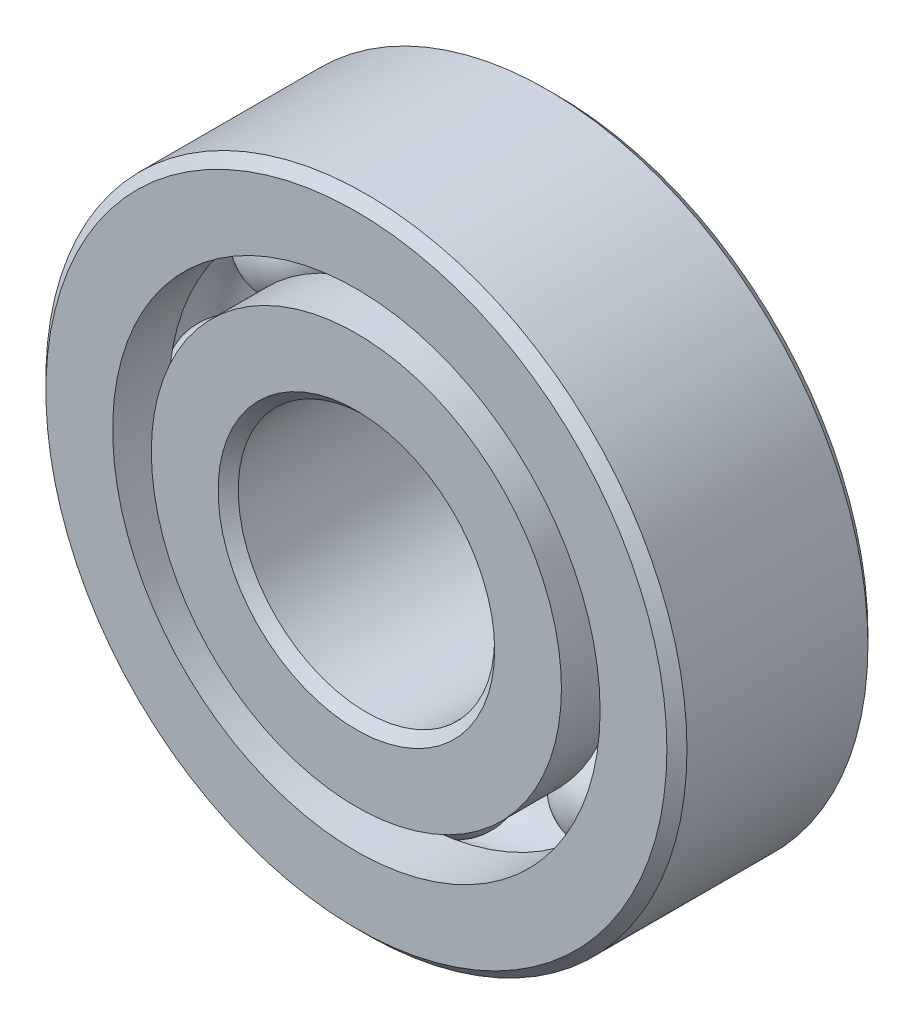
from build123d import *

# Parameters (mm, degrees)
CIRPATTERN1_COUNT = 8


with BuildPart() as part:
    # Sketch1 → Revolve1 (revolve)
    with BuildSketch(Plane(origin=(0, 0, 0), x_dir=(0, 0, -1), z_dir=(1, 0, 0))):
        with BuildLine():
            Line((2.24028, 7.9375), (-2.24028, 7.9375))
            Line((-2.24028, 7.9375), (-2.4892, 7.68858))
            Line((-2.4892, 7.68858), (-2.4892, 6.035221429))
            Line((-2.4892, 6.035221429), (-1.106311111, 6.035221429))
            ThreePointArc((-1.106311111, 6.035221429), (0, 6.76179465), (1.106311111, 6.035221429))
            Line((1.106311111, 6.035221429), (2.4892, 6.035221429))
            Line((2.4892, 6.035221429), (2.4892, 7.68858))
            Line((2.4892, 7.68858), (2.24028, 7.9375))
        make_face()
    revolve(axis=Axis((0, 0, 2.4892), (0, 0, -1)))


with BuildPart() as body_2:
    # Sketch3 → Revolve3 (revolve)
    with BuildSketch(Plane(origin=(0, 0, 0), x_dir=(0, 0, -1), z_dir=(1, 0, 0))):
        with BuildLine():
            Line((-2.4892, 5.077278571), (-1.106311111, 5.077278571))
            ThreePointArc((-1.106311111, 5.077278571), (0, 4.35070535), (1.106311111, 5.077278571))
            Line((1.106311111, 5.077278571), (2.4892, 5.077278571))
            Line((2.4892, 5.077278571), (2.4892, 3.42392))
            Line((2.4892, 3.42392), (2.24028, 3.175))
            Line((2.24028, 3.175), (-2.24028, 3.175))
            Line((-2.24028, 3.175), (-2.4892, 3.42392))
            Line((-2.4892, 3.42392), (-2.4892, 5.077278571))
        make_face()
    revolve(axis=Axis((0, 0, 2.4892), (0, 0, -1)))


with BuildPart() as body_3:
    # Sketch4 → Revolve4 (revolve)
    with BuildSketch(Plane(origin=(0, 0, 0), x_dir=(0, 0, -1), z_dir=(1, 0, 0))):
        with BuildLine():
            Line((-1.20554465, 5.55625), (1.20554465, 5.55625))
            ThreePointArc((1.20554465, 5.55625), (0, 6.76179465), (-1.20554465, 5.55625))
        make_face()
    revolve(axis=Axis((0, 5.55625, 1.20554465), (0, 0, -1)))


with BuildPart() as cirpattern1_1:
    # CirPattern1: pattern copy
    add(body_3.part.rotate(Axis((0, 0, 0), (0, 0, 1)), 1 * 360 / CIRPATTERN1_COUNT))


with BuildPart() as cirpattern1_2:
    # CirPattern1: pattern copy
    add(body_3.part.rotate(Axis((0, 0, 0), (0, 0, 1)), 2 * 360 / CIRPATTERN1_COUNT))


with BuildPart() as cirpattern1_3:
    # CirPattern1: pattern copy
    add(body_3.part.rotate(Axis((0, 0, 0), (0, 0, 1)), 3 * 360 / CIRPATTERN1_COUNT))


with BuildPart() as cirpattern1_4:
    # CirPattern1: pattern copy
    add(body_3.part.rotate(Axis((0, 0, 0), (0, 0, 1)), 4 * 360 / CIRPATTERN1_COUNT))


with BuildPart() as cirpattern1_5:
    # CirPattern1: pattern copy
    add(body_3.part.rotate(Axis((0, 0, 0), (0, 0, 1)), 5 * 360 / CIRPATTERN1_COUNT))


with BuildPart() as cirpattern1_6:
    # CirPattern1: pattern copy
    add(body_3.part.rotate(Axis((0, 0, 0), (0, 0, 1)), 6 * 360 / CIRPATTERN1_COUNT))


with BuildPart() as cirpattern1_7:
    # CirPattern1: pattern copy
    add(body_3.part.rotate(Axis((0, 0, 0), (0, 0, 1)), 7 * 360 / CIRPATTERN1_COUNT))


solid = Compound([part.part, body_2.part, body_3.part, cirpattern1_1.part, cirpattern1_2.part, cirpattern1_3.part, cirpattern1_4.part, cirpattern1_5.part, cirpattern1_6.part, cirpattern1_7.part])
